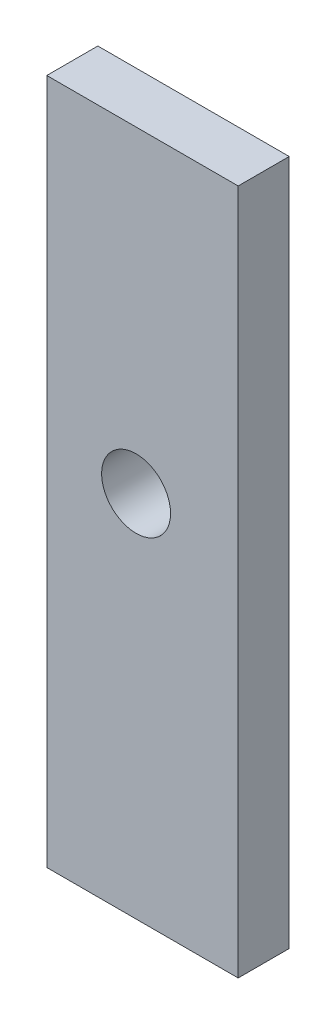
from build123d import *

# Parameters (mm, degrees)
SKETCH1_W           = 7.5
SKETCH1_H           = 26.881
SKETCH1_R           = 1.35
BOSS_EXTRUDE1_DEPTH = 2


with BuildPart() as part:
    # Sketch1 → Boss-Extrude1 (new body)
    with BuildSketch(Plane.XY):
        with Locations((0.25, -1.0005)):
            Rectangle(SKETCH1_W, SKETCH1_H)
        Circle(SKETCH1_R, mode=Mode.SUBTRACT)
    extrude(amount=BOSS_EXTRUDE1_DEPTH)


solid = part.part
